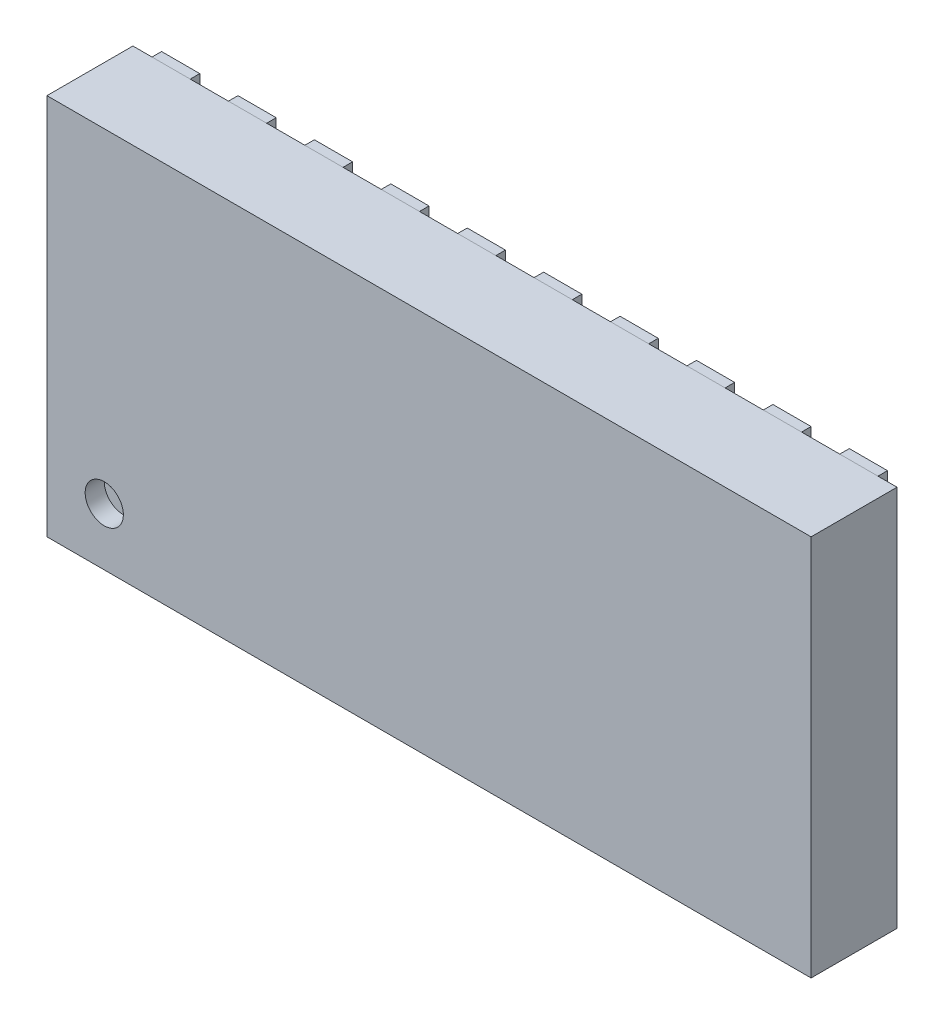
from build123d import *

# Parameters (mm, degrees)
SKETCH1_W              = 4
SKETCH1_H              = 2
BOSS_EXTRUDE1_DEPTH    = 0.45
SKETCH2_W              = 0.2
SKETCH2_H              = 0.55
BOSS_EXTRUDE2_DEPTH    = 0.05
BOSS_EXTRUDE2_2_DEPTH  = 0.05
BOSS_EXTRUDE2_3_DEPTH  = 0.05
BOSS_EXTRUDE2_4_DEPTH  = 0.05
BOSS_EXTRUDE2_5_DEPTH  = 0.05
BOSS_EXTRUDE2_6_DEPTH  = 0.05
BOSS_EXTRUDE2_7_DEPTH  = 0.05
BOSS_EXTRUDE2_8_DEPTH  = 0.05
BOSS_EXTRUDE2_9_DEPTH  = 0.05
BOSS_EXTRUDE2_10_DEPTH = 0.05
BOSS_EXTRUDE2_11_DEPTH = 0.05
BOSS_EXTRUDE2_12_DEPTH = 0.05
BOSS_EXTRUDE2_13_DEPTH = 0.05
BOSS_EXTRUDE2_14_DEPTH = 0.05
BOSS_EXTRUDE2_15_DEPTH = 0.05
BOSS_EXTRUDE2_16_DEPTH = 0.05
BOSS_EXTRUDE2_17_DEPTH = 0.05
BOSS_EXTRUDE2_18_DEPTH = 0.05
BOSS_EXTRUDE2_19_DEPTH = 0.05
BOSS_EXTRUDE2_20_DEPTH = 0.05
SKETCH3_R              = 0.1
CUT_EXTRUDE1_DEPTH     = 0.1


with BuildPart() as part:
    # Sketch1 → Boss-Extrude1 (new body)
    with BuildSketch(Plane.XY):
        with Locations((2, 1)):
            Rectangle(SKETCH1_W, SKETCH1_H)
    extrude(amount=BOSS_EXTRUDE1_DEPTH)

    # Sketch3 → Cut-Extrude1 (cut)
    with BuildSketch(Plane.XY.offset(0.45)):
        with Locations((0.3, 0.3)):
            Circle(SKETCH3_R)
    extrude(amount=-CUT_EXTRUDE1_DEPTH, mode=Mode.SUBTRACT)


with BuildPart() as body_2:
    # Sketch2 → Boss-Extrude2 (new body)
    with BuildSketch(Plane(origin=(0, 0, 0), x_dir=(-1, 0, 0), z_dir=(0, 0, -1))):
        with Locations((-3.8, 1.725)):
            Rectangle(SKETCH2_W, SKETCH2_H)
    extrude(amount=BOSS_EXTRUDE2_DEPTH)


with BuildPart() as body_3:
    # Sketch2 → Boss-Extrude2 2 (new body)
    with BuildSketch(Plane(origin=(0, 0, 0), x_dir=(-1, 0, 0), z_dir=(0, 0, -1))):
        with Locations((-3.4, 1.725)):
            Rectangle(SKETCH2_W, SKETCH2_H)
    extrude(amount=BOSS_EXTRUDE2_2_DEPTH)


with BuildPart() as body_4:
    # Sketch2 → Boss-Extrude2 3 (new body)
    with BuildSketch(Plane(origin=(0, 0, 0), x_dir=(-1, 0, 0), z_dir=(0, 0, -1))):
        with Locations((-3, 1.725)):
            Rectangle(SKETCH2_W, SKETCH2_H)
    extrude(amount=BOSS_EXTRUDE2_3_DEPTH)


with BuildPart() as body_5:
    # Sketch2 → Boss-Extrude2 4 (new body)
    with BuildSketch(Plane(origin=(0, 0, 0), x_dir=(-1, 0, 0), z_dir=(0, 0, -1))):
        with Locations((-2.6, 1.725)):
            Rectangle(SKETCH2_W, SKETCH2_H)
    extrude(amount=BOSS_EXTRUDE2_4_DEPTH)


with BuildPart() as body_6:
    # Sketch2 → Boss-Extrude2 5 (new body)
    with BuildSketch(Plane(origin=(0, 0, 0), x_dir=(-1, 0, 0), z_dir=(0, 0, -1))):
        with Locations((-2.2, 1.725)):
            Rectangle(SKETCH2_W, SKETCH2_H)
    extrude(amount=BOSS_EXTRUDE2_5_DEPTH)


with BuildPart() as body_7:
    # Sketch2 → Boss-Extrude2 6 (new body)
    with BuildSketch(Plane(origin=(0, 0, 0), x_dir=(-1, 0, 0), z_dir=(0, 0, -1))):
        with Locations((-1.8, 1.725)):
            Rectangle(SKETCH2_W, SKETCH2_H)
    extrude(amount=BOSS_EXTRUDE2_6_DEPTH)


with BuildPart() as body_8:
    # Sketch2 → Boss-Extrude2 7 (new body)
    with BuildSketch(Plane(origin=(0, 0, 0), x_dir=(-1, 0, 0), z_dir=(0, 0, -1))):
        with Locations((-1.4, 1.725)):
            Rectangle(SKETCH2_W, SKETCH2_H)
    extrude(amount=BOSS_EXTRUDE2_7_DEPTH)


with BuildPart() as body_9:
    # Sketch2 → Boss-Extrude2 8 (new body)
    with BuildSketch(Plane(origin=(0, 0, 0), x_dir=(-1, 0, 0), z_dir=(0, 0, -1))):
        with Locations((-1, 1.725)):
            Rectangle(SKETCH2_W, SKETCH2_H)
    extrude(amount=BOSS_EXTRUDE2_8_DEPTH)


with BuildPart() as body_10:
    # Sketch2 → Boss-Extrude2 9 (new body)
    with BuildSketch(Plane(origin=(0, 0, 0), x_dir=(-1, 0, 0), z_dir=(0, 0, -1))):
        with Locations((-0.6, 1.725)):
            Rectangle(SKETCH2_W, SKETCH2_H)
    extrude(amount=BOSS_EXTRUDE2_9_DEPTH)


with BuildPart() as body_11:
    # Sketch2 → Boss-Extrude2 10 (new body)
    with BuildSketch(Plane(origin=(0, 0, 0), x_dir=(-1, 0, 0), z_dir=(0, 0, -1))):
        with Locations((-0.2, 1.725)):
            Rectangle(SKETCH2_W, SKETCH2_H)
    extrude(amount=BOSS_EXTRUDE2_10_DEPTH)


with BuildPart() as body_12:
    # Sketch2 → Boss-Extrude2 11 (new body)
    with BuildSketch(Plane(origin=(0, 0, 0), x_dir=(-1, 0, 0), z_dir=(0, 0, -1))):
        Polygon((-0.3, 0), (-0.3, 0.65), (-0.170710678, 0.65), (-0.1, 0.579289322), (-0.1, 0), align=None)
    extrude(amount=BOSS_EXTRUDE2_11_DEPTH)


with BuildPart() as body_13:
    # Sketch2 → Boss-Extrude2 12 (new body)
    with BuildSketch(Plane(origin=(0, 0, 0), x_dir=(-1, 0, 0), z_dir=(0, 0, -1))):
        with Locations((-0.6, 0.275)):
            Rectangle(SKETCH2_W, SKETCH2_H)
    extrude(amount=BOSS_EXTRUDE2_12_DEPTH)


with BuildPart() as body_14:
    # Sketch2 → Boss-Extrude2 13 (new body)
    with BuildSketch(Plane(origin=(0, 0, 0), x_dir=(-1, 0, 0), z_dir=(0, 0, -1))):
        with Locations((-1, 0.275)):
            Rectangle(SKETCH2_W, SKETCH2_H)
    extrude(amount=BOSS_EXTRUDE2_13_DEPTH)


with BuildPart() as body_15:
    # Sketch2 → Boss-Extrude2 14 (new body)
    with BuildSketch(Plane(origin=(0, 0, 0), x_dir=(-1, 0, 0), z_dir=(0, 0, -1))):
        with Locations((-1.4, 0.275)):
            Rectangle(SKETCH2_W, SKETCH2_H)
    extrude(amount=BOSS_EXTRUDE2_14_DEPTH)


with BuildPart() as body_16:
    # Sketch2 → Boss-Extrude2 15 (new body)
    with BuildSketch(Plane(origin=(0, 0, 0), x_dir=(-1, 0, 0), z_dir=(0, 0, -1))):
        with Locations((-1.8, 0.275)):
            Rectangle(SKETCH2_W, SKETCH2_H)
    extrude(amount=BOSS_EXTRUDE2_15_DEPTH)


with BuildPart() as body_17:
    # Sketch2 → Boss-Extrude2 16 (new body)
    with BuildSketch(Plane(origin=(0, 0, 0), x_dir=(-1, 0, 0), z_dir=(0, 0, -1))):
        with Locations((-2.2, 0.275)):
            Rectangle(SKETCH2_W, SKETCH2_H)
    extrude(amount=BOSS_EXTRUDE2_16_DEPTH)


with BuildPart() as body_18:
    # Sketch2 → Boss-Extrude2 17 (new body)
    with BuildSketch(Plane(origin=(0, 0, 0), x_dir=(-1, 0, 0), z_dir=(0, 0, -1))):
        with Locations((-2.6, 0.275)):
            Rectangle(SKETCH2_W, SKETCH2_H)
    extrude(amount=BOSS_EXTRUDE2_17_DEPTH)


with BuildPart() as body_19:
    # Sketch2 → Boss-Extrude2 18 (new body)
    with BuildSketch(Plane(origin=(0, 0, 0), x_dir=(-1, 0, 0), z_dir=(0, 0, -1))):
        with Locations((-3, 0.275)):
            Rectangle(SKETCH2_W, SKETCH2_H)
    extrude(amount=BOSS_EXTRUDE2_18_DEPTH)


with BuildPart() as body_20:
    # Sketch2 → Boss-Extrude2 19 (new body)
    with BuildSketch(Plane(origin=(0, 0, 0), x_dir=(-1, 0, 0), z_dir=(0, 0, -1))):
        with Locations((-3.4, 0.275)):
            Rectangle(SKETCH2_W, SKETCH2_H)
    extrude(amount=BOSS_EXTRUDE2_19_DEPTH)


with BuildPart() as body_21:
    # Sketch2 → Boss-Extrude2 20 (new body)
    with BuildSketch(Plane(origin=(0, 0, 0), x_dir=(-1, 0, 0), z_dir=(0, 0, -1))):
        with Locations((-3.8, 0.275)):
            Rectangle(SKETCH2_W, SKETCH2_H)
    extrude(amount=BOSS_EXTRUDE2_20_DEPTH)


solid = Compound([part.part, body_2.part, body_3.part, body_4.part, body_5.part, body_6.part, body_7.part, body_8.part, body_9.part, body_10.part, body_11.part, body_12.part, body_13.part, body_14.part, body_15.part, body_16.part, body_17.part, body_18.part, body_19.part, body_20.part, body_21.part])
